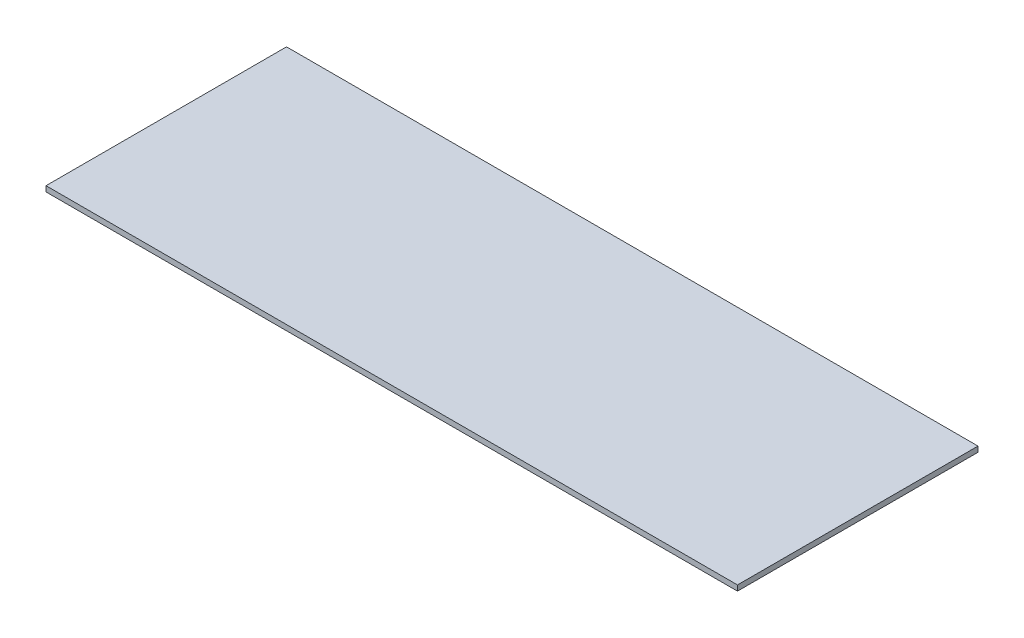
from build123d import *

# Parameters (mm, degrees)
SKETCH1_W           = 2300
SKETCH1_H           = 800
BOSS_EXTRUDE1_DEPTH = 18


with BuildPart() as part:
    # Sketch1 → Boss-Extrude1 (new body)
    with BuildSketch(Plane(origin=(0, 0, 0), x_dir=(1, 0, 0), z_dir=(0, 1, 0))):
        with Locations((1150, 400)):
            Rectangle(SKETCH1_W, SKETCH1_H)
    extrude(amount=BOSS_EXTRUDE1_DEPTH)


solid = part.part
